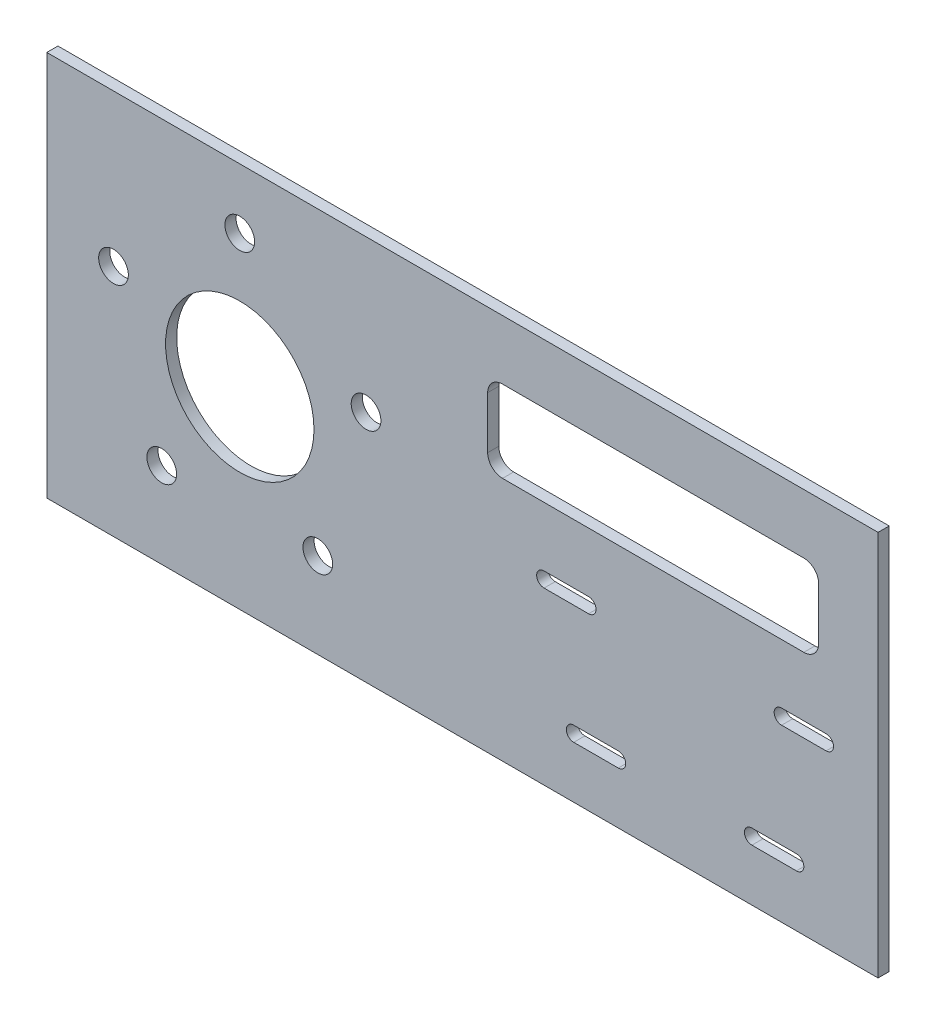
from build123d import *

# Parameters (mm, degrees)
SKETCH2_W           = 355.6
SKETCH2_H           = 165.1
SKETCH2_R           = 31.75
SKETCH2_R_2         = 6.35
BOSS_EXTRUDE1_DEPTH = 4.7625
CUT_EXTRUDE1_DEPTH  = 5.7625
CUT_EXTRUDE3_DEPTH  = 5.7625


with BuildPart() as part:
    # Sketch2 → Boss-Extrude1 (new body)
    with BuildSketch(Plane.XY):
        with Locations((95.25, 0)):
            Rectangle(SKETCH2_W, SKETCH2_H)
        Circle(SKETCH2_R, mode=Mode.SUBTRACT)
        with Locations((-54.018973032, 17.551828308)):
            Circle(SKETCH2_R_2, mode=Mode.SUBTRACT)
        with Locations((0, 56.798909535)):
            Circle(SKETCH2_R_2, mode=Mode.SUBTRACT)
        with Locations((54.018973032, 17.551828308)):
            Circle(SKETCH2_R_2, mode=Mode.SUBTRACT)
        with Locations((33.385561371, -45.951283076)):
            Circle(SKETCH2_R_2, mode=Mode.SUBTRACT)
        with Locations((-33.385561371, -45.951283076)):
            Circle(SKETCH2_R_2, mode=Mode.SUBTRACT)
    extrude(amount=BOSS_EXTRUDE1_DEPTH)

    # Sketch3 → Cut-Extrude1 (cut, through all)
    with BuildSketch(Plane.XY.offset(4.7625)):
        with BuildLine():
            Line((149.225, -9.525), (130.175, -9.525))
            ThreePointArc((130.175, -9.525), (127, -6.35), (130.175, -3.175))
            Line((130.175, -3.175), (149.225, -3.175))
            ThreePointArc((149.225, -3.175), (152.4, -6.35), (149.225, -9.525))
        make_face()
        with BuildLine():
            Line((250.825, -9.525), (231.775, -9.525))
            ThreePointArc((231.775, -9.525), (228.6, -6.35), (231.775, -3.175))
            Line((231.775, -3.175), (250.825, -3.175))
            ThreePointArc((250.825, -3.175), (254, -6.35), (250.825, -9.525))
        make_face()
        with BuildLine():
            Line((238.125, -60.325), (219.075, -60.325))
            ThreePointArc((219.075, -60.325), (215.9, -57.15), (219.075, -53.975))
            Line((219.075, -53.975), (238.125, -53.975))
            ThreePointArc((238.125, -53.975), (241.3, -57.15), (238.125, -60.325))
        make_face()
        with BuildLine():
            Line((142.875, -53.975), (161.925, -53.975))
            ThreePointArc((161.925, -53.975), (165.1, -57.15), (161.925, -60.325))
            Line((161.925, -60.325), (142.875, -60.325))
            ThreePointArc((142.875, -60.325), (139.7, -57.15), (142.875, -53.975))
        make_face()
    extrude(amount=-CUT_EXTRUDE1_DEPTH, mode=Mode.SUBTRACT)

    # Sketch4 → Cut-Extrude3 (cut, through all)
    with BuildSketch(Plane.XY.offset(4.7625)):
        with BuildLine():
            Line((247.65, 28.575), (247.65, 50.8))
            ThreePointArc((247.65, 50.8), (245.790128061, 55.290128061), (241.3, 57.15))
            Line((241.3, 57.15), (112.395, 57.15))
            ThreePointArc((112.395, 57.15), (107.904871939, 55.290128061), (106.045, 50.8))
            Line((106.045, 50.8), (106.045, 28.575))
            ThreePointArc((106.045, 28.575), (107.904871939, 24.084871939), (112.395, 22.225))
            Line((112.395, 22.225), (241.3, 22.225))
            ThreePointArc((241.3, 22.225), (245.790128061, 24.084871939), (247.65, 28.575))
        make_face()
    extrude(amount=-CUT_EXTRUDE3_DEPTH, mode=Mode.SUBTRACT)


solid = part.part
